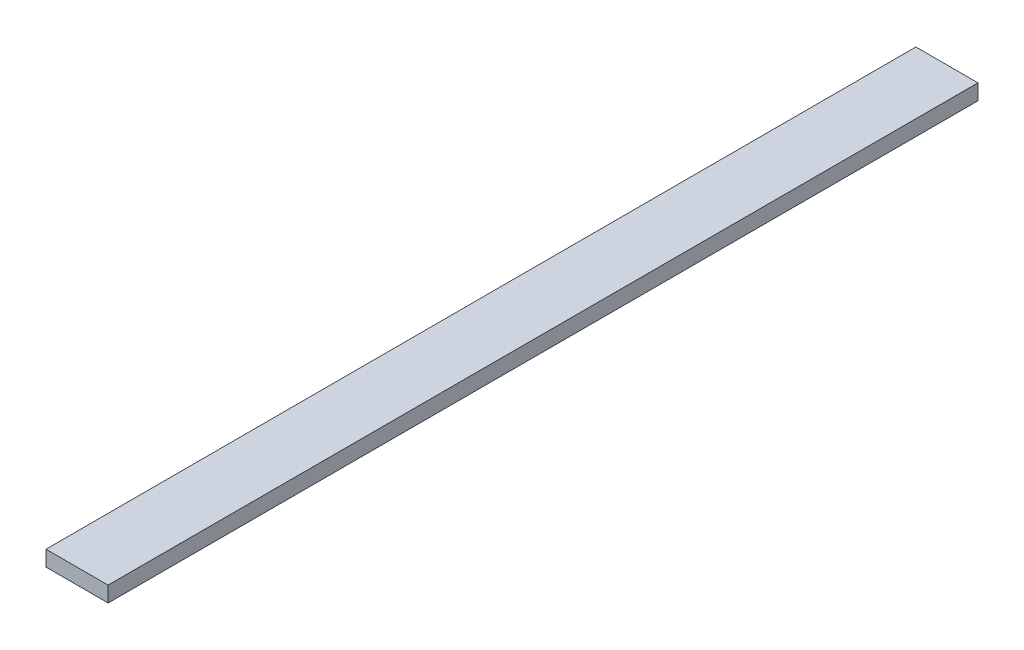
from build123d import *

# Parameters (mm, degrees)
SKETCH1_W           = 25.4
SKETCH1_H           = 355.6
BOSS_EXTRUDE1_DEPTH = 6.35


with BuildPart() as part:
    # Sketch1 → Boss-Extrude1 (new body)
    with BuildSketch(Plane(origin=(0, 0, 0), x_dir=(1, 0, 0), z_dir=(0, 1, 0))):
        with Locations((12.7, 177.8)):
            Rectangle(SKETCH1_W, SKETCH1_H)
    extrude(amount=BOSS_EXTRUDE1_DEPTH)


solid = part.part
